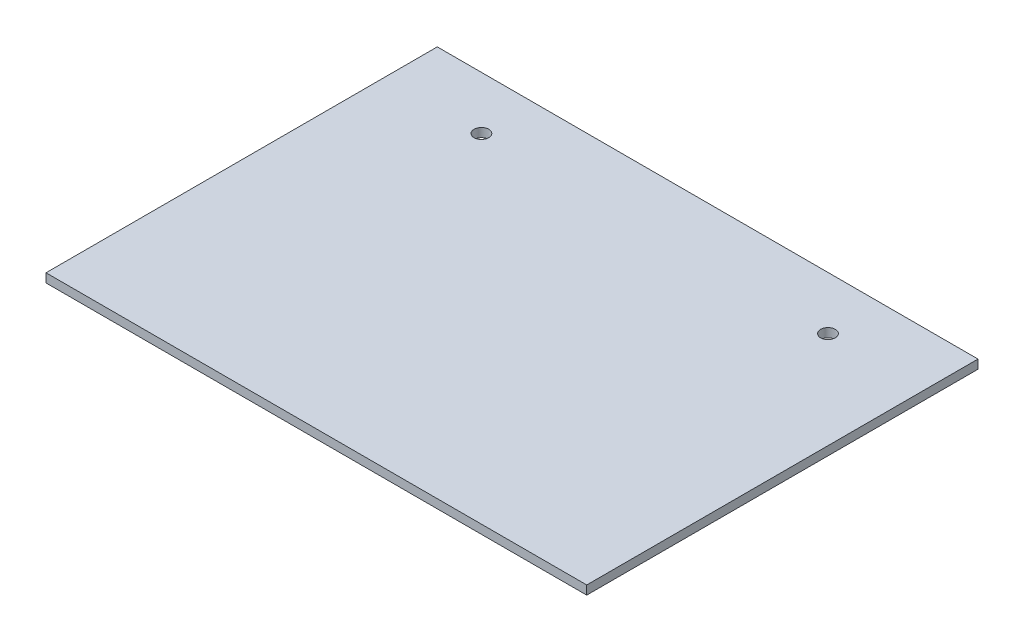
from build123d import *

# Parameters (mm, degrees)
SKETCH2_W           = 183.8
SKETCH2_H           = 133
SKETCH2_W_2         = 177.8
SKETCH2_H_2         = 127
SKETCH2_R           = 2.5
BOSS_EXTRUDE1_DEPTH = 3


with BuildPart() as part:
    # Sketch2 → Boss-Extrude1 (new body)
    with BuildSketch(Plane(origin=(0, 0, 0), x_dir=(1, 0, 0), z_dir=(0, 1, 0))):
        with Locations((-88.9, 63.5)):
            Rectangle(SKETCH2_W, SKETCH2_H)
        with Locations((-88.9, 63.5)):
            Rectangle(SKETCH2_W_2, SKETCH2_H_2, mode=Mode.SUBTRACT)
        with Locations((-88.9, 63.5)):
            Rectangle(SKETCH2_W_2, SKETCH2_H_2)
        with Locations(Location((-30, 112, 0), (0, 0, 270))):
            Circle(SKETCH2_R, mode=Mode.SUBTRACT)
        with Locations(Location((-147.8, 112, 0), (0, 0, 270))):
            Circle(SKETCH2_R, mode=Mode.SUBTRACT)
    extrude(amount=BOSS_EXTRUDE1_DEPTH)


solid = part.part
